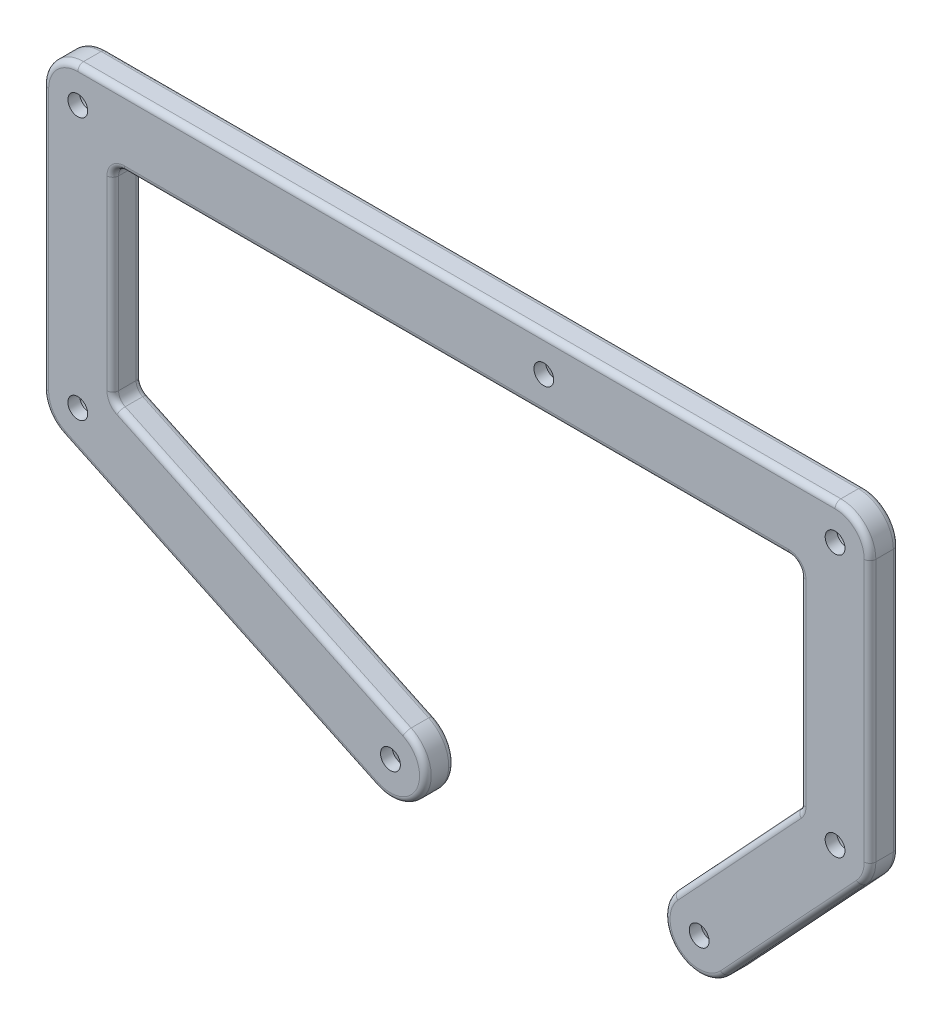
from build123d import *

# Parameters (mm, degrees)
ESQUISSE2_R             = 1.7
BOSS_EXTRU_1_DEPTH      = 5
ENL_V_START             = -5
ESQUISSE3_R             = 3.25
ENL_V_MAT_EXTRU_1_DEPTH = 3
CONG_1_R                = 2
CONG_2_R                = 1


with BuildPart() as part:
    # Esquisse2 → Boss.-Extru.1 (new body)
    with BuildSketch(Plane.XY):
        with BuildLine():
            Line((-80, 76.1), (50, 76.1))
            ThreePointArc((50, 76.1), (54.242640687, 74.342640687), (56, 70.1))
            Line((56, 70.1), (56, 25.1))
            ThreePointArc((56, 25.1), (55.584289984, 22.905528452), (54.394764876, 21.015144839))
            Line((54.394764876, 21.015144839), (31.064764876, -4.084855161))
            ThreePointArc((31.064764876, -4.084855161), (22.585144839, -4.394764876), (22.275235124, 4.084855161))
            Line((22.275235124, 4.084855161), (44, 27.457834089))
            Line((44, 27.457834089), (44, 64.1))
            Line((44, 64.1), (-74, 64.1))
            Line((-74, 64.1), (-74, 31.1))
            Line((-74, 31.1), (-74, 28.899715343))
            Line((-74, 28.899715343), (-23.765001412, 5.144092758))
            ThreePointArc((-23.765001412, 5.144092758), (-20.905907242, -2.844998588), (-28.894998588, -5.704092758))
            Line((-28.894998588, -5.704092758), (-82.564998588, 19.675907242))
            ThreePointArc((-82.564998588, 19.675907242), (-85.069023157, 21.889859156), (-86, 25.1))
            Line((-86, 25.1), (-86, 70.1))
            ThreePointArc((-86, 70.1), (-84.242640687, 74.342640687), (-80, 76.1))
        make_face()
        with Locations((0, 70.1)):
            Circle(ESQUISSE2_R, mode=Mode.SUBTRACT)
        with Locations((-26.33, -0.28)):
            Circle(ESQUISSE2_R, mode=Mode.SUBTRACT)
        with Locations((26.67, 0)):
            Circle(ESQUISSE2_R, mode=Mode.SUBTRACT)
        with Locations((-80, 25.1)):
            Circle(ESQUISSE2_R, mode=Mode.SUBTRACT)
        with Locations((50, 25.1)):
            Circle(ESQUISSE2_R, mode=Mode.SUBTRACT)
        with Locations((50, 70.1)):
            Circle(ESQUISSE2_R, mode=Mode.SUBTRACT)
        with Locations((-80, 70.1)):
            Circle(ESQUISSE2_R, mode=Mode.SUBTRACT)
    extrude(amount=-BOSS_EXTRU_1_DEPTH)

    # Esquisse3 → Enlèv. mat.-Extru.1 (cut)
    with BuildSketch(Plane.XY.offset(ENL_V_START)):
        with Locations((-80, 70.1)):
            Circle(ESQUISSE3_R)
        with Locations((-80, 25.1)):
            Circle(ESQUISSE3_R)
        with Locations((50, 25.1)):
            Circle(ESQUISSE3_R)
        with Locations((50, 70.1)):
            Circle(ESQUISSE3_R)
        Polygon((-27.975448267, 2.57), (-24.684551733, 2.57), (-23.039103466, -0.28), (-24.684551733, -3.13), (-27.975448267, -3.13), (-29.620896534, -0.28), align=None)
        Polygon((25.024551733, 2.85), (28.315448267, 2.85), (29.960896534, 0), (28.315448267, -2.85), (25.024551733, -2.85), (23.379103466, 0), align=None)
        Polygon((-1.645448267, 72.95), (1.645448267, 72.95), (3.290896534, 70.1), (1.645448267, 67.25), (-1.645448267, 67.25), (-3.290896534, 70.1), align=None)
    extrude(amount=ENL_V_MAT_EXTRU_1_DEPTH, mode=Mode.SUBTRACT)

    # Congé1
    cong_1_edges = [part.edges().sort_by_distance(p)[0] for p in [
        (44, 64.1, -2.5),
        (-74, 64.1, -2.5),
        (-74, 28.899715343, -2.5),
        (44, 27.457834089, -2.5),
    ]]
    fillet(cong_1_edges, radius=CONG_1_R)

    # Congé2
    cong_2_edges = [part.edges().sort_by_distance(p)[0] for p in [
        (22.585144839, -4.394764876, -5),
        (44, 45.171889392, 0),
        (44, 45.171889392, -5),
        (42.729764876, 8.465144839, -5),
        (32.870078375, 15.48350778, 0),
        (32.870078375, 15.48350778, -5),
        (-74, 46.133143562, 0),
        (-74, 46.133143562, -5),
        (-15, 64.1, 0),
        (-15, 64.1, -5),
        (43.861429995, 27.512288269, 0),
        (43.861429995, 27.512288269, -5),
        (-48.310000471, 16.751174481, 0),
        (-73.689674386, 29.096240176, 0),
        (-73.689674386, 29.096240176, -5),
        (-73.414213562, 63.514213562, 0),
        (-73.414213562, 63.514213562, -5),
        (43.414213562, 63.514213562, 0),
        (43.414213562, 63.514213562, -5),
        (-20.905907242, -2.844998588, 0),
        (-55.729998588, 6.985907242, 0),
        (-85.069023157, 21.889859156, 0),
        (-86, 47.6, 0),
        (-84.242640687, 74.342640687, 0),
        (-15, 76.1, 0),
        (54.242640687, 74.342640687, 0),
        (55.584289984, 22.905528452, -5),
        (56, 47.6, 0),
        (55.584289984, 22.905528452, 0),
        (42.729764876, 8.465144839, 0),
        (22.585144839, -4.394764876, 0),
        (56, 47.6, -5),
        (54.242640687, 74.342640687, -5),
        (-15, 76.1, -5),
        (-84.242640687, 74.342640687, -5),
        (-86, 47.6, -5),
        (-85.069023157, 21.889859156, -5),
        (-55.729998588, 6.985907242, -5),
        (-20.905907242, -2.844998588, -5),
        (-48.310000471, 16.751174481, -5),
    ]]
    fillet(cong_2_edges, radius=CONG_2_R)


solid = part.part
